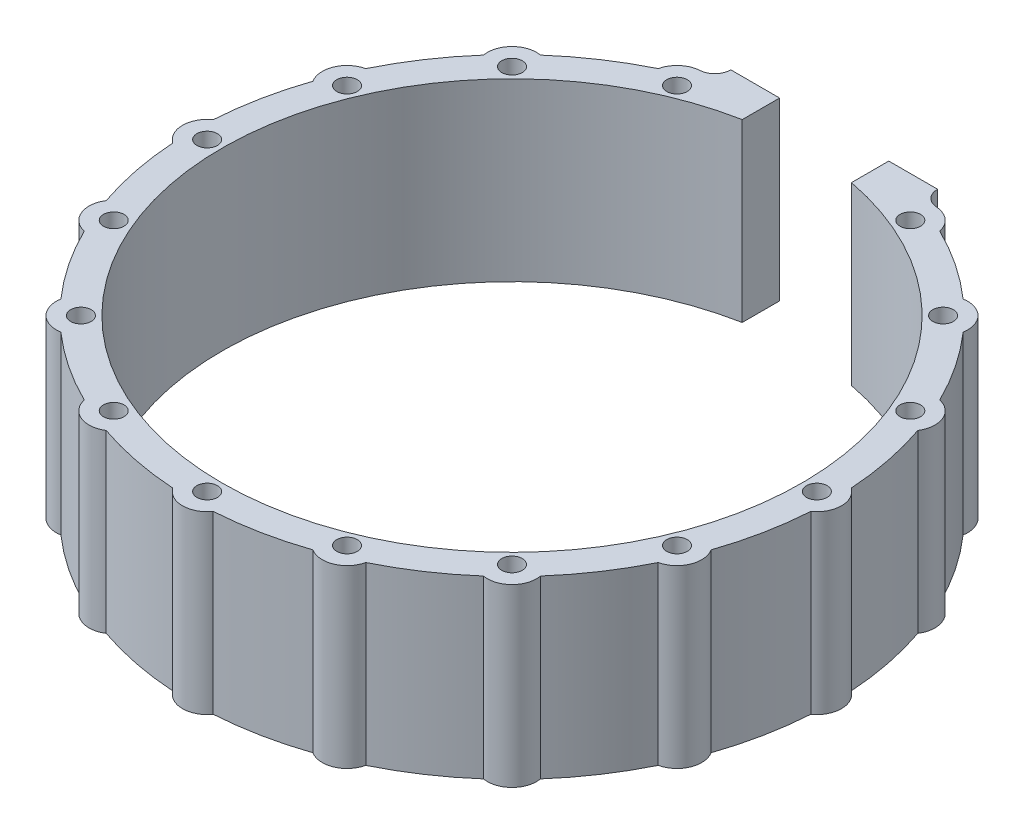
from build123d import *

# Parameters (mm, degrees)
BOSS_EXTRUDE1_START = -14.125
SKETCH1_R           = 1.651
BOSS_EXTRUDE1_DEPTH = 28.25


with BuildPart() as part:
    # Sketch1 → Boss-Extrude1 (new body)
    with BuildSketch(Plane(origin=(0, 0, 0), x_dir=(1, 0, 0), z_dir=(0, 1, 0)).offset(BOSS_EXTRUDE1_START)):
        with BuildLine():
            Line((-8.776779323, 45.790197737), (-8.776779323, 51.79824794))
            Line((-8.776779323, 51.79824794), (-16.623069776, 51.79824794))
            Line((-16.623069776, 51.79824794), (-16.623069776, 51.770561205))
            ThreePointArc((-16.623069776, 51.770561205), (-17.311358259, 50.031951284), (-19.00319927, 49.235597414))
            ThreePointArc((-19.00319927, 49.235597414), (-21.332823655, 48.290932405), (-22.627542979, 46.136113705))
            ThreePointArc((-22.627542979, 46.136113705), (-28.548670887, 42.726105365), (-33.965025348, 38.560650178))
            ThreePointArc((-33.965025348, 38.560650178), (-37.45809785, 37.45809785), (-38.560650178, 33.965025348))
            ThreePointArc((-38.560650178, 33.965025348), (-42.726105365, 28.548670887), (-46.136113705, 22.627542979))
            ThreePointArc((-46.136113705, 22.627542979), (-48.941363385, 20.272176475), (-48.62324794, 16.623069776))
            ThreePointArc((-48.62324794, 16.623069776), (-50.398877615, 10.02496006), (-51.283396975, 3.249597481))
            ThreePointArc((-51.283396975, 3.249597481), (-52.97375, 0), (-51.283396975, -3.249597481))
            ThreePointArc((-51.283396975, -3.249597481), (-50.398877615, -10.02496006), (-48.62324794, -16.623069776))
            ThreePointArc((-48.62324794, -16.623069776), (-48.941363385, -20.272176475), (-46.136113705, -22.627542979))
            ThreePointArc((-46.136113705, -22.627542979), (-42.726105365, -28.548670887), (-38.560650178, -33.965025348))
            ThreePointArc((-38.560650178, -33.965025348), (-37.45809785, -37.45809785), (-33.965025348, -38.560650178))
            ThreePointArc((-33.965025348, -38.560650178), (-28.548670887, -42.726105365), (-22.627542979, -46.136113705))
            ThreePointArc((-22.627542979, -46.136113705), (-20.272176475, -48.941363385), (-16.623069776, -48.62324794))
            ThreePointArc((-16.623069776, -48.62324794), (-10.02496006, -50.398877615), (-3.249597481, -51.283396975))
            ThreePointArc((-3.249597481, -51.283396975), (0, -52.97375), (3.249597481, -51.283396975))
            ThreePointArc((3.249597481, -51.283396975), (10.02496006, -50.398877615), (16.623069776, -48.62324794))
            ThreePointArc((16.623069776, -48.62324794), (20.272176475, -48.941363385), (22.627542979, -46.136113705))
            ThreePointArc((22.627542979, -46.136113705), (28.548670887, -42.726105365), (33.965025348, -38.560650178))
            ThreePointArc((33.965025348, -38.560650178), (37.45809785, -37.45809785), (38.560650178, -33.965025348))
            ThreePointArc((38.560650178, -33.965025348), (42.726105365, -28.548670887), (46.136113705, -22.627542979))
            ThreePointArc((46.136113705, -22.627542979), (48.941363385, -20.272176475), (48.62324794, -16.623069776))
            ThreePointArc((48.62324794, -16.623069776), (50.398877615, -10.02496006), (51.283396975, -3.249597481))
            ThreePointArc((51.283396975, -3.249597481), (52.97375, 0), (51.283396975, 3.249597481))
            ThreePointArc((51.283396975, 3.249597481), (50.398877615, 10.02496006), (48.62324794, 16.623069776))
            ThreePointArc((48.62324794, 16.623069776), (48.941363385, 20.272176475), (46.136113705, 22.627542979))
            ThreePointArc((46.136113705, 22.627542979), (42.726105365, 28.548670887), (38.560650178, 33.965025348))
            ThreePointArc((38.560650178, 33.965025348), (37.45809785, 37.45809785), (33.965025348, 38.560650178))
            ThreePointArc((33.965025348, 38.560650178), (28.548670887, 42.726105365), (22.627542979, 46.136113705))
            ThreePointArc((22.627542979, 46.136113705), (21.332823655, 48.290932405), (19.00319927, 49.235597414))
            ThreePointArc((19.00319927, 49.235597414), (17.311358259, 50.031951284), (16.623069776, 51.770561205))
            Line((16.623069776, 51.770561205), (16.623069776, 51.79824794))
            Line((16.623069776, 51.79824794), (8.776779323, 51.79824794))
            Line((8.776779323, 51.79824794), (8.776779323, 45.790197737))
            ThreePointArc((8.776779323, 45.790197737), (0, -46.62375), (-8.776779323, 45.790197737))
        make_face()
        with Locations((18.753401603, 45.274716491)):
            Circle(SKETCH1_R, mode=Mode.SUBTRACT)
        with Locations((34.651767812, 34.651767812)):
            Circle(SKETCH1_R, mode=Mode.SUBTRACT)
        with Locations((45.274716491, 18.753401603)):
            Circle(SKETCH1_R, mode=Mode.SUBTRACT)
        with Locations((49.005, 0)):
            Circle(SKETCH1_R, mode=Mode.SUBTRACT)
        with Locations((45.274716491, -18.753401603)):
            Circle(SKETCH1_R, mode=Mode.SUBTRACT)
        with Locations((34.651767812, -34.651767812)):
            Circle(SKETCH1_R, mode=Mode.SUBTRACT)
        with Locations((18.753401603, -45.274716491)):
            Circle(SKETCH1_R, mode=Mode.SUBTRACT)
        with Locations((0, -49.005)):
            Circle(SKETCH1_R, mode=Mode.SUBTRACT)
        with Locations((-18.753401603, -45.274716491)):
            Circle(SKETCH1_R, mode=Mode.SUBTRACT)
        with Locations((-34.651767812, -34.651767812)):
            Circle(SKETCH1_R, mode=Mode.SUBTRACT)
        with Locations((-45.274716491, -18.753401603)):
            Circle(SKETCH1_R, mode=Mode.SUBTRACT)
        with Locations((-49.005, 0)):
            Circle(SKETCH1_R, mode=Mode.SUBTRACT)
        with Locations((-45.274716491, 18.753401603)):
            Circle(SKETCH1_R, mode=Mode.SUBTRACT)
        with Locations((-34.651767812, 34.651767812)):
            Circle(SKETCH1_R, mode=Mode.SUBTRACT)
        with Locations((-18.753401603, 45.274716491)):
            Circle(SKETCH1_R, mode=Mode.SUBTRACT)
    extrude(amount=BOSS_EXTRUDE1_DEPTH)


solid = part.part
